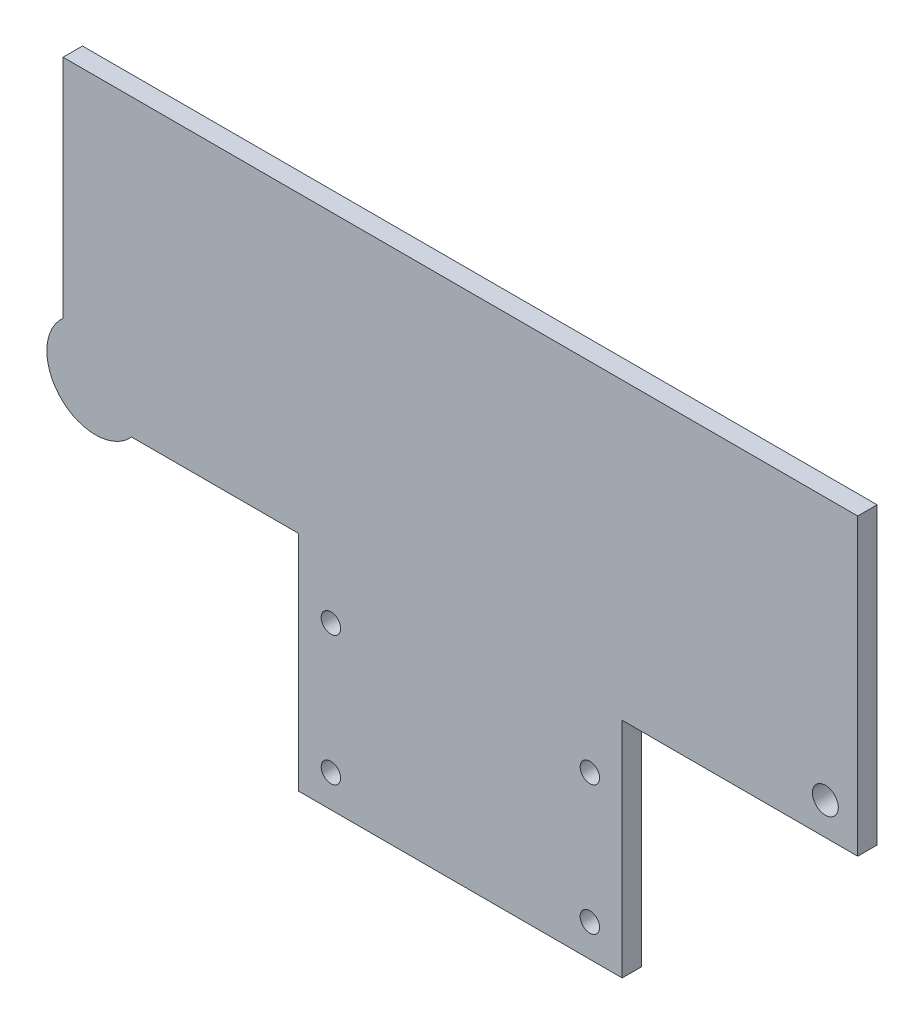
from build123d import *

# Parameters (mm, degrees)
ESQUISSE1_R             = 2
ESQUISSE1_R_2           = 1.5
BOSS_EXTRU_1_DEPTH      = 3
BOSS_EXTRU_2_START      = -3
ESQUISSE3_R             = 7.5
BOSS_EXTRU_2_DEPTH      = 6
ESQUISSE4_R             = 3.875
ENL_V_MAT_EXTRU_1_DEPTH = 1
ESQUISSE5_R             = 2.375
ENL_V_MAT_EXTRU_2_DEPTH = 4


with BuildPart() as part:
    # Esquisse1 → Boss.-Extru.1 (new body)
    with BuildSketch(Plane.XY):
        Polygon((-61.381557247, 0), (61.381557247, 0), (61.381557247, -45.5212086), (25, -45.5212086), (25, -80), (-25, -80), (-25, -45.5212086), (-61.381557247, -45.5212086), align=None)
        with Locations((0, -20)):
            Circle(ESQUISSE1_R, mode=Mode.SUBTRACT)
        with Locations((-20, -55)):
            Circle(ESQUISSE1_R_2, mode=Mode.SUBTRACT)
        with Locations((20, -55)):
            Circle(ESQUISSE1_R_2, mode=Mode.SUBTRACT)
        with Locations((20, -75)):
            Circle(ESQUISSE1_R_2, mode=Mode.SUBTRACT)
        with Locations((-20, -75)):
            Circle(ESQUISSE1_R_2, mode=Mode.SUBTRACT)
        with Locations((56.381557247, -40.5212086)):
            Circle(ESQUISSE1_R, mode=Mode.SUBTRACT)
        with Locations((-56.381557247, -40.5212086)):
            Circle(ESQUISSE1_R, mode=Mode.SUBTRACT)
    extrude(amount=BOSS_EXTRU_1_DEPTH)

    # Esquisse3 → Boss.-Extru.2 (add)
    with BuildSketch(Plane(origin=(0, 0, 0), x_dir=(-1, 0, 0), z_dir=(0, 0, -1)).offset(BOSS_EXTRU_2_START)):
        with Locations((56.381557247, -40.5212086)):
            Circle(ESQUISSE3_R)
        with Locations((0, -20)):
            Circle(ESQUISSE3_R)
    extrude(amount=BOSS_EXTRU_2_DEPTH)

    # Esquisse4 → Enlèv. mat.-Extru.1 (cut)
    with BuildSketch(Plane(origin=(0, 0, -3), x_dir=(-1, 0, 0), z_dir=(0, 0, -1))):
        with Locations((56.381557247, -40.5212086)):
            Circle(ESQUISSE4_R)
        with Locations((0, -20)):
            Circle(ESQUISSE4_R)
    extrude(amount=-ENL_V_MAT_EXTRU_1_DEPTH, mode=Mode.SUBTRACT)

    # Esquisse5 → Enlèv. mat.-Extru.2 (cut)
    with BuildSketch(Plane(origin=(0, 0, -2), x_dir=(-1, 0, 0), z_dir=(0, 0, -1))):
        with Locations((56.381557247, -40.5212086)):
            Circle(ESQUISSE5_R)
        with Locations((0, -20)):
            Circle(ESQUISSE5_R)
    extrude(amount=-ENL_V_MAT_EXTRU_2_DEPTH, mode=Mode.SUBTRACT)


solid = part.part
